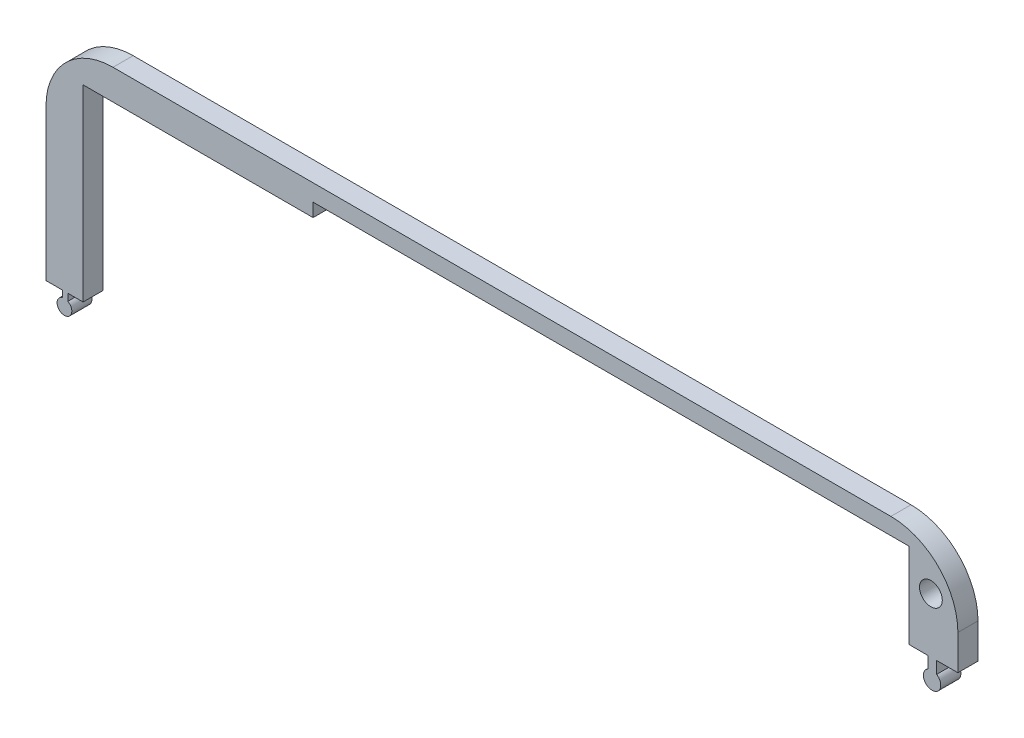
from build123d import *

# Parameters (mm, degrees)
BOSS_EXTRUDE1_DEPTH  = 3
M3_CLEARANCE_HOLE1_D = 3.4
SKETCH2_OUTSIDE_W    = 168.672
SKETCH2_OUTSIDE_H    = 102.608
CUT_EXTRUDE1_DEPTH   = 10


with BuildPart() as part:
    # Sketch1 → Boss-Extrude1 (new body)
    with BuildSketch(Plane.XY):
        with BuildLine():
            Line((-93.536600288, 73.798841742), (22.52665856, 73.798841742))
            ThreePointArc((22.52665856, 73.798841742), (29.597726372, 76.72777393), (32.52665856, 83.798841742))
            Line((32.52665856, 83.798841742), (32.52665856, 133.798841742))
            ThreePointArc((32.52665856, 133.798841742), (29.597726372, 140.869909554), (22.52665856, 143.798841742))
            Line((22.52665856, 143.798841742), (-93.536600288, 143.798841742))
            ThreePointArc((-93.536600288, 143.798841742), (-100.6076681, 140.869909554), (-103.536600288, 133.798841742))
            Line((-103.536600288, 133.798841742), (-103.536600288, 83.798841742))
            ThreePointArc((-103.536600288, 83.798841742), (-100.6076681, 76.72777393), (-93.536600288, 73.798841742))
        make_face()
        Polygon((7.241251279, 79.113754803), (7.241251279, 115.298841742), (25.200464445, 115.298841742), (25.200464445, 141.298841742), (-63.686125174, 141.298841742), (-63.686125174, 139.298841742), (-98, 139.298841742), (-98, 79.113754803), align=None, mode=Mode.SUBTRACT)
    extrude(amount=BOSS_EXTRUDE1_DEPTH)

    # M3 Clearance Hole1 (through all)
    with Locations(Plane(origin=(0, 0, 0), x_dir=(-1, 0, 0), z_dir=(0, 0, -1))):
        with Locations((-28.497536526, 136.798841742), (-28.497536526, 81.798841742)):
            Hole(M3_CLEARANCE_HOLE1_D / 2)

    # Sketch2 outside → Cut-Extrude1 (cut)
    with BuildSketch(Plane.XY.offset(3)):
        with Locations((-35.505, 108.799)):
            Rectangle(SKETCH2_OUTSIDE_W, SKETCH2_OUTSIDE_H)
        with BuildLine():
            Line((-98, 111.232980273), (-100.276015927, 111.232980273))
            Line((-100.276015927, 111.232980273), (-100.276015927, 110.181279495))
            ThreePointArc((-100.276015927, 110.181279495), (-100.885260547, 108.11074669), (-101.110575194, 110.257259772))
            Line((-101.110575194, 110.257259772), (-101.110575194, 111.232980273))
            Line((-101.110575194, 111.232980273), (-103.536600288, 111.232980273))
            Line((-103.536600288, 111.232980273), (-103.536600288, 155.169137996))
            Line((-103.536600288, 155.169137996), (37.520914888, 146.495442913))
            Line((37.520914888, 146.495442913), (36.419995989, 128.591552724))
            Line((36.419995989, 128.591552724), (32.52665856, 128.591552724))
            Line((32.52665856, 128.591552724), (29.357018022, 128.591552724))
            Line((29.357018022, 128.591552724), (29.357018022, 126.79555932))
            ThreePointArc((29.357018022, 126.79555932), (28.609769319, 124.402587901), (28.09640217, 126.856390462))
            Line((28.09640217, 126.856390462), (28.09640217, 128.591552724))
            Line((28.09640217, 128.591552724), (25.200464445, 128.591552724))
            Line((25.200464445, 128.591552724), (-98, 111.232980273))
        make_face(mode=Mode.SUBTRACT)
    extrude(amount=-CUT_EXTRUDE1_DEPTH, mode=Mode.SUBTRACT)


solid = part.part
